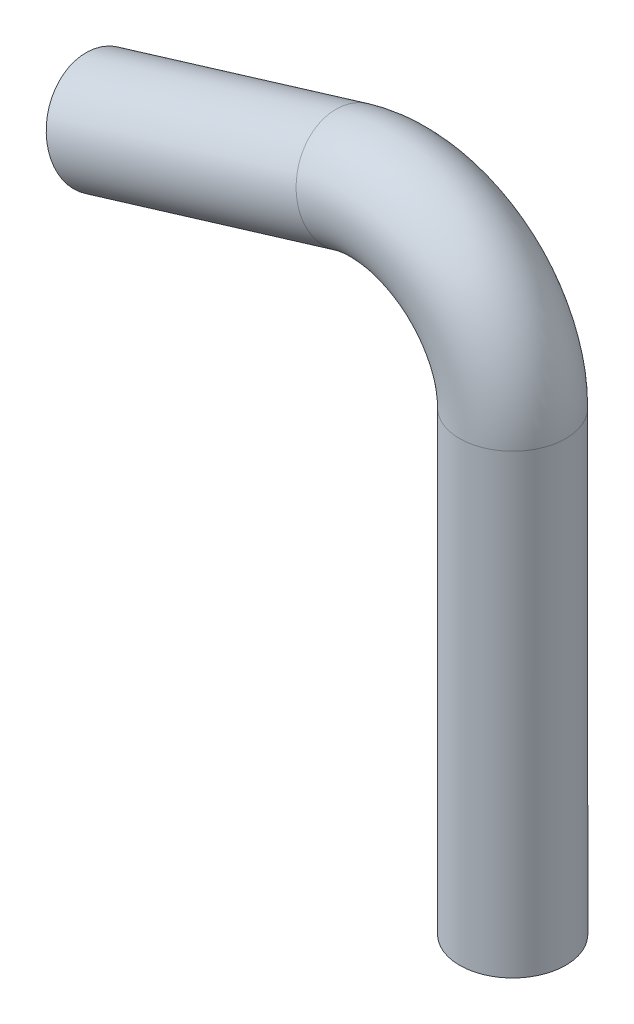
from build123d import *

# Parameters (mm, degrees)
SKETCH1_R   = 21.59
SKETCH1_R_2 = 19.05


with BuildPart() as part:
    # Sweep1: sweep along a path in Sketch17
    with BuildLine(Plane.XY) as sweep1_path:
        Line((0, 0), (0, 185.469049607))
        ThreePointArc((0, 185.469049607), (-20.548471474, 226.279403952), (-65.57027645, 234.074388137))
        Line((-65.57027645, 234.074388137), (-167.17027645, 203.2))
    # Sketch1 → Sweep1 (sweep)
    with BuildSketch(Plane(origin=(0, 0, 0), x_dir=(1, 0, 0), z_dir=(0, 1, 0))):
        Circle(SKETCH1_R)
        Circle(SKETCH1_R_2, mode=Mode.SUBTRACT)
    sweep(path=sweep1_path.line)


solid = part.part
